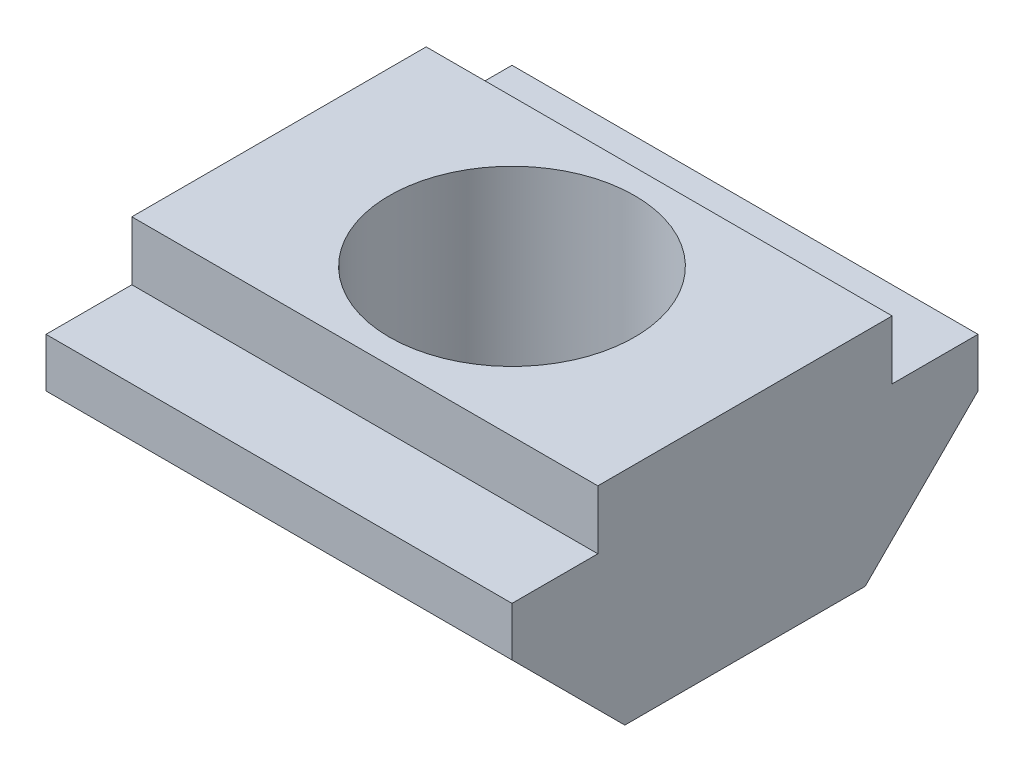
from build123d import *

# Parameters (mm, degrees)
SKETCH_1_W          = 9.5
SKETCH_1_H          = 9.5
EXTRUDE_1_DEPTH     = 3.3
SKETCH_2_W          = 9.5
SKETCH_2_H          = 6
EXTRUDE_2_DEPTH     = 1.2
SKETCH_3_R          = 2.5
CUT_EXTRUDE_1_DEPTH = 5.5
CUT_EXTRUDE_2_DEPTH = 10.5


with BuildPart() as part:
    # 草图1 → 凸台-拉伸1 (new body)
    with BuildSketch(Plane(origin=(0, 0, 0), x_dir=(1, 0, 0), z_dir=(0, 1, 0))):
        with Locations((4.75, 4.75)):
            Rectangle(SKETCH_1_W, SKETCH_1_H)
    extrude(amount=EXTRUDE_1_DEPTH)

    # 草图2 → 凸台-拉伸2 (add)
    with BuildSketch(Plane(origin=(0, 3.3, 0), x_dir=(1, 0, 0), z_dir=(0, 1, 0))):
        with Locations((4.75, 4.75)):
            Rectangle(SKETCH_2_W, SKETCH_2_H)
    extrude(amount=EXTRUDE_2_DEPTH)

    # 草图3 → 切除-拉伸1 (cut, through all)
    with BuildSketch(Plane(origin=(0, 4.5, 0), x_dir=(1, 0, 0), z_dir=(0, 1, 0))):
        with Locations((4.75, 4.75)):
            Circle(SKETCH_3_R)
    extrude(amount=-CUT_EXTRUDE_1_DEPTH, mode=Mode.SUBTRACT)

    # 草图4 → 切除-拉伸2 (cut, through all)
    with BuildSketch(Plane.ZY):
        Polygon((-9.5, 2.3), (-7.2, 0), (-9.5, 0), align=None)
        Polygon((0, 2.3), (-2.3, 0), (0, 0), align=None)
    extrude(amount=-CUT_EXTRUDE_2_DEPTH, mode=Mode.SUBTRACT)


solid = part.part
